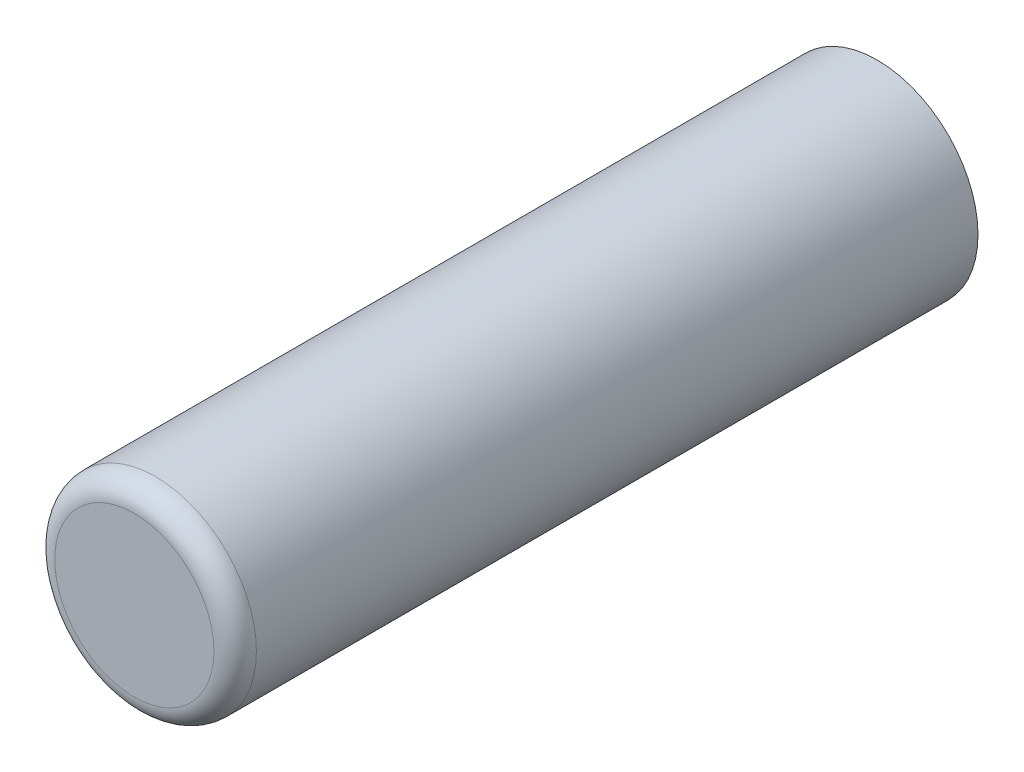
from build123d import *

# Parameters (mm, degrees)
SKETCH1_R           = 3.8
BOSS_EXTRUDE1_DEPTH = 14
FILLET1_R           = 0.8


with BuildPart() as part:
    # Sketch1 → Boss-Extrude1 (new body, symmetric)
    with BuildSketch(Plane.XY):
        Circle(SKETCH1_R)
    extrude(amount=BOSS_EXTRUDE1_DEPTH, both=True)

    # Fillet1
    fillet1_edges = [part.edges().sort_by_distance(p)[0] for p in [
        (-3.8, 0, 14),
    ]]
    fillet(fillet1_edges, radius=FILLET1_R)


solid = part.part
